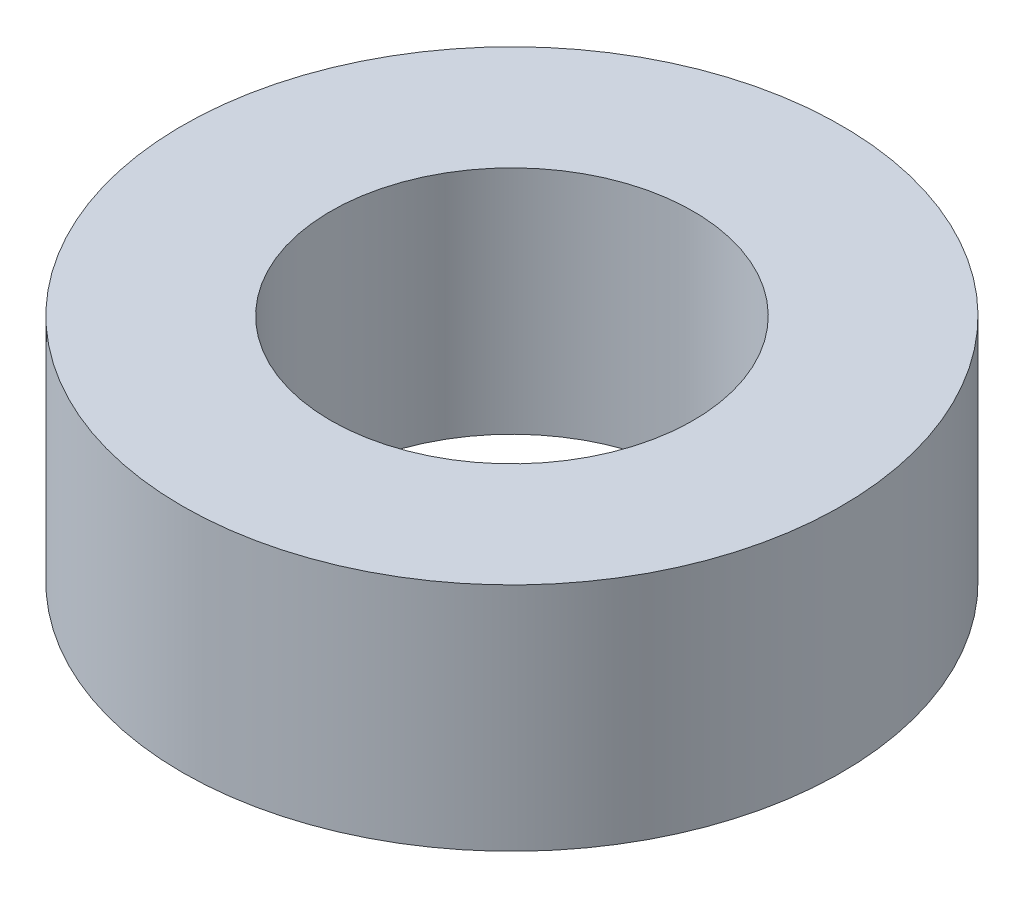
from build123d import *

# Parameters (mm, degrees)
SKETCH1_R           = 3
SKETCH1_R_2         = 1.65
BOSS_EXTRUDE1_DEPTH = 2.1


with BuildPart() as part:
    # Sketch1 → Boss-Extrude1 (new body)
    with BuildSketch(Plane(origin=(0, 0, 0), x_dir=(1, 0, 0), z_dir=(0, 1, 0))):
        Circle(SKETCH1_R)
        Circle(SKETCH1_R_2, mode=Mode.SUBTRACT)
    extrude(amount=BOSS_EXTRUDE1_DEPTH)


solid = part.part
